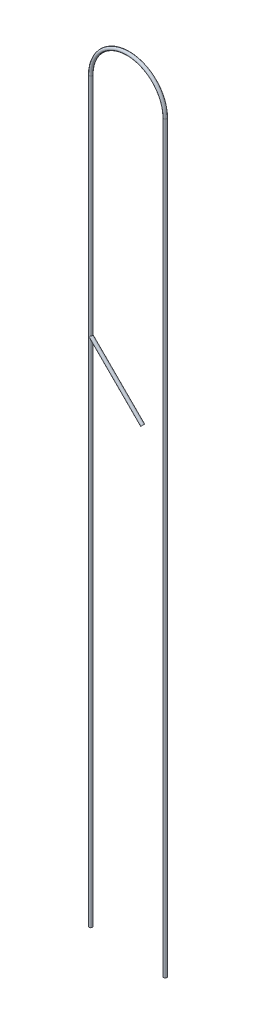
from build123d import *

# Parameters (mm, degrees)
SWEEP_THIN1_PROFILE_R   = 30
SWEEP_THIN1_PROFILE_R_2 = 27
SWEEP_THIN2_PROFILE_R   = 30
SWEEP_THIN2_PROFILE_R_2 = 27


with BuildPart() as part:
    # Sweep-Thin1: sweep along a curve in space
    with BuildLine() as sweep_thin1_path:
        Line((-21650.561141738, -2253.469371448, 40322.600196057), (-21650.561141738, 11528.530628552, 40322.600196057))
        ThreePointArc((-23030.561141738, 11528.530628552, 40322.600196057), (-22340.561141738, 12218.530628552, 40322.600196057), (-21650.561141738, 11528.530628552, 40322.600196057))
        Line((-23030.561141738, 11528.530628552, 40322.600196057), (-23030.561141738, -2137.129962978, 40322.600196057))
    # Sweep-Thin1 profile (on start of the path) → Sweep-Thin1 (sweep)
    with BuildSketch(Plane(origin=(-21650.561141738, -2253.469371448, 40322.600196057), x_dir=(0, 0, 1), z_dir=(0, 1, 0))):
        Circle(SWEEP_THIN1_PROFILE_R)
        Circle(SWEEP_THIN1_PROFILE_R_2, mode=Mode.SUBTRACT)
    sweep(path=sweep_thin1_path.line)

    # Sweep-Thin2: sweep along a curve in space
    with BuildLine() as sweep_thin2_path:
        Line((-23030.561141738, 7347.973694777, 40322.600196057), (-22069.11834597, 6386.53089901, 40322.600196057))
    # Sweep-Thin2 profile (on start of the path) → Sweep-Thin2 (sweep)
    with BuildSketch(Plane(origin=(-23030.561141738, 7347.973694777, 40322.600196057), x_dir=(-0.7071067811865512, -0.7071067811865438, 0), z_dir=(0.7071067811865438, -0.7071067811865512, -2.568579135240447e-13))):
        Circle(SWEEP_THIN2_PROFILE_R)
        Circle(SWEEP_THIN2_PROFILE_R_2, mode=Mode.SUBTRACT)
    sweep(path=sweep_thin2_path.line)


solid = part.part
